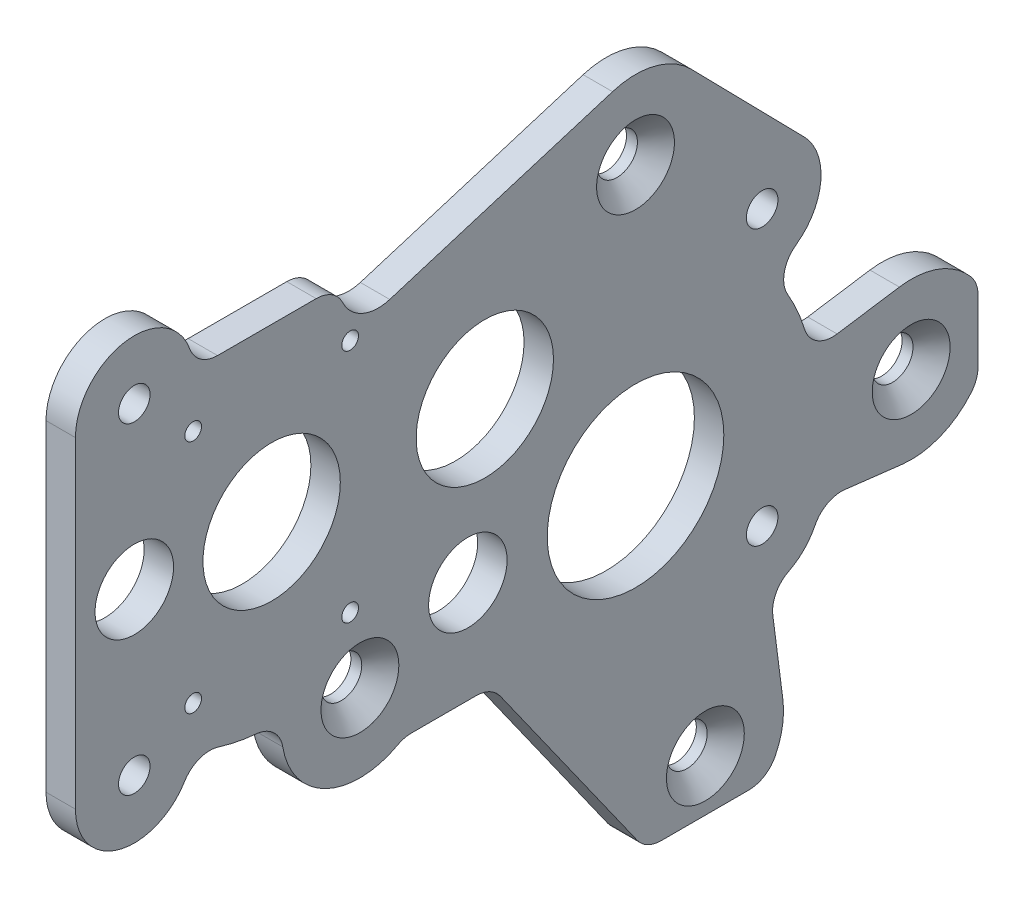
from build123d import *

# Parameters (mm, degrees)
SKETCH1_W                                      = 146.05
SKETCH1_H                                      = 127
BOSS_EXTRUDE2_DEPTH                            = 4.7625
SKETCH2_R                                      = 14.2875
SKETCH2_R_2                                    = 11.1125
CUT_EXTRUDE1_DEPTH                             = 5.7625
CSK_FOR_M6_FLAT_HEAD_MACHINE_SCREW1_AT_2_COUNT = 2
CSK_FOR_M6_FLAT_HEAD_MACHINE_SCREW1_AT_2_PITCH = 89.21849584
CSK_FOR_M6_FLAT_HEAD_MACHINE_SCREW1_AT_3_COUNT = 2
CSK_FOR_M6_FLAT_HEAD_MACHINE_SCREW1_AT_3_PITCH = 67.750719553
CSK_FOR_M6_FLAT_HEAD_MACHINE_SCREW1_AT_4_COUNT = 2
CSK_FOR_M6_FLAT_HEAD_MACHINE_SCREW1_AT_4_PITCH = 67.750719553
F_10_CLEARANCE_HOLE2_D                         = 5.1054
FILLET2_R                                      = 9.525
F_6_32_TAPPED_HOLE1_D                          = 2.7051
SKETCH11_R                                     = 6.35
CUT_EXTRUDE2_DEPTH                             = 5.7625
FILLET28_R                                     = 4.7625


with BuildPart() as part:
    # Sketch1 → Boss-Extrude2 (new body)
    with BuildSketch(Plane(origin=(0, 0, 0), x_dir=(0, 0, -1), z_dir=(1, 0, 0))):
        with Locations((73.025, 63.5)):
            Rectangle(SKETCH1_W, SKETCH1_H)
    extrude(amount=BOSS_EXTRUDE2_DEPTH)

    # Sketch2 → Cut-Extrude1 (cut, through all)
    with BuildSketch(Plane(origin=(4.7625, 0, 0), x_dir=(0, 0, -1), z_dir=(1, 0, 0))):
        with Locations((90.633575625, 51.809624375)):
            Circle(SKETCH2_R)
        with Locations((31.75, 76.2)):
            Circle(SKETCH2_R_2)
        with Locations((66.2432, 76.2)):
            Circle(SKETCH2_R_2)
    extrude(amount=-CUT_EXTRUDE1_DEPTH, mode=Mode.SUBTRACT)

    # Sketch4 → CSK for M6 Flat Head Machine Screw1 (revolve, cut)
    with BuildSketch(Plane(origin=(4.7625, 96.809624375, -90.633575625), x_dir=(0, 0, -1), z_dir=(0, 1, 0))):
        Polygon((0, 0), (0, 4.7625), (3.3, 4.7625), (3.3, 3), (6.3, 0), align=None)
    csk_for_m6_flat_head_machine_screw1 = revolve(axis=Axis((11.1125, 96.809624375, -90.633575625), (-1, 0, 0)), mode=Mode.SUBTRACT)

    # CSK for M6 Flat Head Machine Screw1 at 2: CSK for M6 Flat Head Machine Screw1 ×2
    with Locations(*[Vector(0, -0.991946784, -0.126655352) * (i * CSK_FOR_M6_FLAT_HEAD_MACHINE_SCREW1_AT_2_PITCH) for i in range(1, CSK_FOR_M6_FLAT_HEAD_MACHINE_SCREW1_AT_2_COUNT)]):
        add(csk_for_m6_flat_head_machine_screw1, mode=Mode.SUBTRACT)

    # CSK for M6 Flat Head Machine Screw1 at 3: CSK for M6 Flat Head Machine Screw1 ×2
    with Locations(*[Vector(0, -0.752759533, 0.658295591) * (i * CSK_FOR_M6_FLAT_HEAD_MACHINE_SCREW1_AT_3_PITCH) for i in range(1, CSK_FOR_M6_FLAT_HEAD_MACHINE_SCREW1_AT_3_COUNT)]):
        add(csk_for_m6_flat_head_machine_screw1, mode=Mode.SUBTRACT)

    # CSK for M6 Flat Head Machine Screw1 at 4: CSK for M6 Flat Head Machine Screw1 ×2
    with Locations(*[Vector(0, -0.752759533, -0.658295591) * (i * CSK_FOR_M6_FLAT_HEAD_MACHINE_SCREW1_AT_4_PITCH) for i in range(1, CSK_FOR_M6_FLAT_HEAD_MACHINE_SCREW1_AT_4_COUNT)]):
        add(csk_for_m6_flat_head_machine_screw1, mode=Mode.SUBTRACT)

    # #10 Clearance Hole2 (through all)
    with Locations(Plane(origin=(4.7625, 0, 0), x_dir=(0, 0, -1), z_dir=(1, 0, 0))):
        with Locations((111.125, 35.934624375), (9.525, 103.879624375), (111.125, 80.384624375), (9.525, 51.809624375)):
            Hole(F_10_CLEARANCE_HOLE2_D / 2)

    # Fillet2
    fillet2_edges = [part.edges().sort_by_distance(p)[0] for p in [
        (2.38125, 127, 0),
        (2.38125, 127, -146.05),
        (2.38125, 0, -146.05),
        (2.38125, 0, 0),
    ]]
    fillet(fillet2_edges, radius=FILLET2_R)

    # #6-32 Tapped Hole1 (through all)
    with Locations(Plane.ZY):
        with Locations((-31.75, 76.2), (-19.05, 57.15), (-44.45, 57.15), (-44.45, 95.25), (-19.05, 95.25)):
            Hole(F_6_32_TAPPED_HOLE1_D / 2)

    # Sketch11 → Cut-Extrude2 (cut, through all)
    with BuildSketch(Plane(origin=(4.7625, 0, 0), x_dir=(0, 0, -1), z_dir=(1, 0, 0))):
        with Locations((9.525, 77.844624375)):
            Circle(SKETCH11_R)
        with Locations((63.5, 51.809624375)):
            Circle(SKETCH11_R)
        with BuildLine():
            Line((19.05, 103.879624375), (42.6466, 103.879624375))
            ThreePointArc((42.6466, 103.879624375), (45.223903728, 98.77185942), (50.863690659, 97.81031861))
            Line((50.863690659, 97.81031861), (86.914095809, 108.900446097))
            ThreePointArc((86.914095809, 108.900446097), (93.741933528, 109.07178614), (99.663642833, 105.66854001))
            Line((99.663642833, 105.66854001), (117.92431938, 87.055072709))
            ThreePointArc((117.92431938, 87.055072709), (120.050883489, 77.059834316), (111.903571622, 70.89149785))
            ThreePointArc((111.903571622, 70.89149785), (116.471992165, 64.012364056), (118.882504918, 56.114112587))
            Line((118.882504918, 56.114112587), (133.328001666, 58.315274614))
            ThreePointArc((133.328001666, 58.315274614), (140.589870378, 57.26966829), (146.05, 52.369156655))
            Line((146.05, 52.369156655), (146.05, 127))
            Line((146.05, 127), (0, 127))
            Line((0, 127), (0, 103.879624375))
            ThreePointArc((0, 103.879624375), (9.525, 113.404624375), (19.05, 103.879624375))
        make_face()
        with BuildLine():
            Line((112.343545309, 26.487890954), (114.479631034, 9.927954891))
            ThreePointArc((114.479631034, 9.927954891), (114.040060834, 4.641448277), (111.471533621, 0))
            Line((111.471533621, 0), (146.05, 0))
            Line((146.05, 0), (146.05, 39.250092095))
            ThreePointArc((146.05, 39.250092095), (140.778077608, 34.439444176), (133.741328545, 33.247948585))
            Line((133.741328545, 33.247948585), (120.583495012, 34.811015408))
            ThreePointArc((120.583495012, 34.811015408), (117.893928842, 29.233338877), (112.343545309, 26.487890954))
        make_face()
        with BuildLine():
            Line((91.611269982, 0.997134634), (67.316588768, 35.291490433))
            Line((67.316588768, 35.291490433), (53.0614742, 35.291490433))
            ThreePointArc((53.0614742, 35.291490433), (39.259729687, 35.126108511), (33.522617739, 47.680034163))
            ThreePointArc((33.522617739, 47.680034163), (26.054731603, 48.198311785), (18.97770782, 50.638326004))
            ThreePointArc((18.97770782, 50.638326004), (8.938236412, 42.302714599), (0, 51.809624375))
            Line((0, 51.809624375), (0, 0))
            Line((0, 0), (92.395617628, 0))
            ThreePointArc((92.395617628, 0), (91.990935768, 0.488728475), (91.611269982, 0.997134634))
        make_face()
    extrude(amount=-CUT_EXTRUDE2_DEPTH, mode=Mode.SUBTRACT)

    # Fillet28
    fillet28_edges = [part.edges().sort_by_distance(p)[0] for p in [
        (2.38125, 103.879624375, -19.05),
        (2.38125, 103.879624375, -42.6466),
        (2.38125, 70.89149785, -111.903571622),
        (2.38125, 56.114112587, -118.882504918),
        (2.38125, 39.250092095, -146.05),
        (2.38125, 52.369156655, -146.05),
        (2.38125, 34.811015408, -120.583495012),
        (2.38125, 26.487890954, -112.343545309),
        (2.38125, 0, -111.471533621),
        (2.38125, 0, -92.395617628),
        (2.38125, 35.291490433, -67.316588768),
        (2.38125, 35.291490433, -53.0614742),
        (2.38125, 47.680034163, -33.522617739),
        (2.38125, 50.638326004, -18.97770782),
    ]]
    fillet(fillet28_edges, radius=FILLET28_R)


solid = part.part
